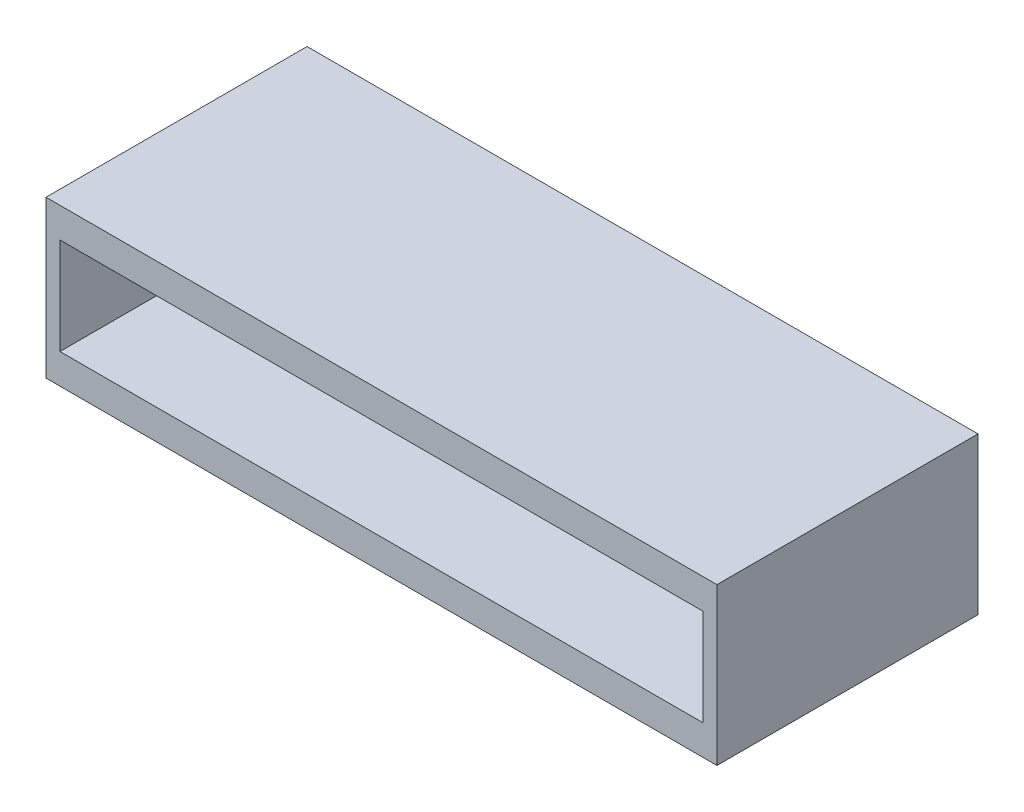
from build123d import *

# Parameters (mm, degrees)
SKETCH1_W           = 12.85
SKETCH1_H           = 5
BOSS_EXTRUDE1_DEPTH = 1.5
SKETCH3_W           = 12.31491511
SKETCH3_H           = 1.85
CUT_EXTRUDE1_DEPTH  = 3.5


with BuildPart() as part:
    # Sketch1 → Boss-Extrude1 (new body, symmetric)
    with BuildSketch(Plane(origin=(0, 0, 0), x_dir=(1, 0, 0), z_dir=(0, 1, 0))):
        Rectangle(SKETCH1_W, SKETCH1_H)
    extrude(amount=BOSS_EXTRUDE1_DEPTH, both=True)

    # Sketch3 → Cut-Extrude1 (cut)
    with BuildSketch(Plane.XY.offset(2.5)):
        Rectangle(SKETCH3_W, SKETCH3_H)
    extrude(amount=-CUT_EXTRUDE1_DEPTH, mode=Mode.SUBTRACT)


solid = part.part
